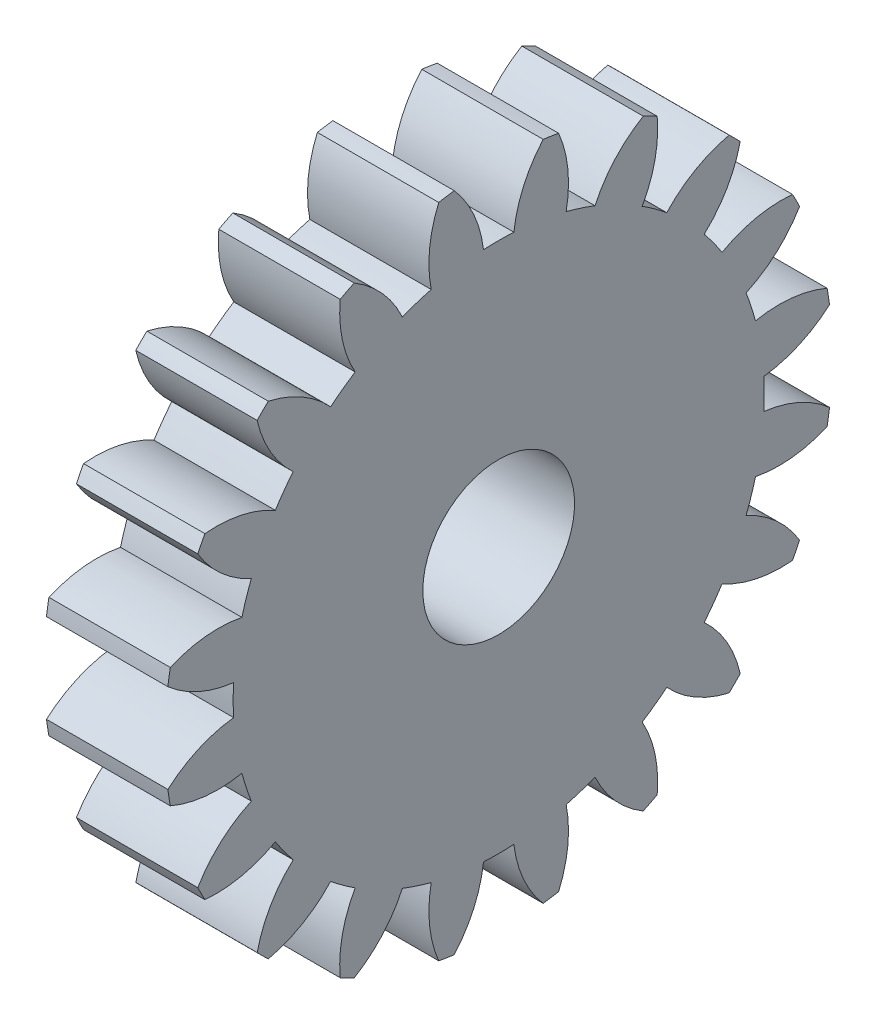
from build123d import *

# Parameters (mm, degrees)
BASPROSKE_W     = 4
BASPROSKE_H     = 11
TOOTHCUT_DEPTH  = 17.062378404
TEETHCUTS_COUNT = 20
TEETHCUTS_ANGLE = 342
BORSKE_R        = 2.5
BORE_DEPTH      = 50.0000508


with BuildPart() as part:
    # BasProSke → Base-Revolve (revolve)
    with BuildSketch(Plane(origin=(0, 0, 0), x_dir=(1, 0, 0), z_dir=(0, 1, 0)), mode=Mode.PRIVATE) as base_revolve_sk:
        with Locations((2, 5.5)):
            Rectangle(BASPROSKE_W, BASPROSKE_H)
    revolve(base_revolve_sk.sketch.rotate(Axis((-10, 0, 0), (1, 0, 0)), 180), axis=Axis((-10, 0, 0), (1, 0, 0)))

    # TooCutSke → ToothCut (cut, through all)
    with BuildSketch(Plane(origin=(0, 0, 0), x_dir=(0, 0, -1), z_dir=(1, 0, 0))):
        with BuildLine():
            ThreePointArc((0.499924007, 8.734705318), (0, 8.749), (-0.499924007, 8.734705318))
            ThreePointArc((-0.499924007, 8.734705318), (-0.824302243, 9.905497836), (-1.485192705, 10.924909509))
            ThreePointArc((-1.485192705, 10.924909509), (0, 11.0254), (1.485192705, 10.924909509))
            ThreePointArc((1.485192705, 10.924909509), (0.824302243, 9.905497836), (0.499924007, 8.734705318))
        make_face()
    toothcut = extrude(amount=TOOTHCUT_DEPTH, mode=Mode.SUBTRACT)

    # TeethCuts: ToothCut ×20 about axis
    teethcuts_axis = Axis((-10, 0, 0), (1, 0, 0))
    for i in range(1, TEETHCUTS_COUNT):
        add(toothcut.rotate(teethcuts_axis, i * TEETHCUTS_ANGLE / (TEETHCUTS_COUNT - 1)), mode=Mode.SUBTRACT)

    # BorSke → Bore (cut, symmetric)
    with BuildSketch(Plane(origin=(0, 0, 0), x_dir=(0, 0, -1), z_dir=(1, 0, 0))):
        with Locations(Location((0, 0, 0), (0, 0, 180))):
            Circle(BORSKE_R)
    extrude(amount=BORE_DEPTH, both=True, mode=Mode.SUBTRACT)


solid = part.part
